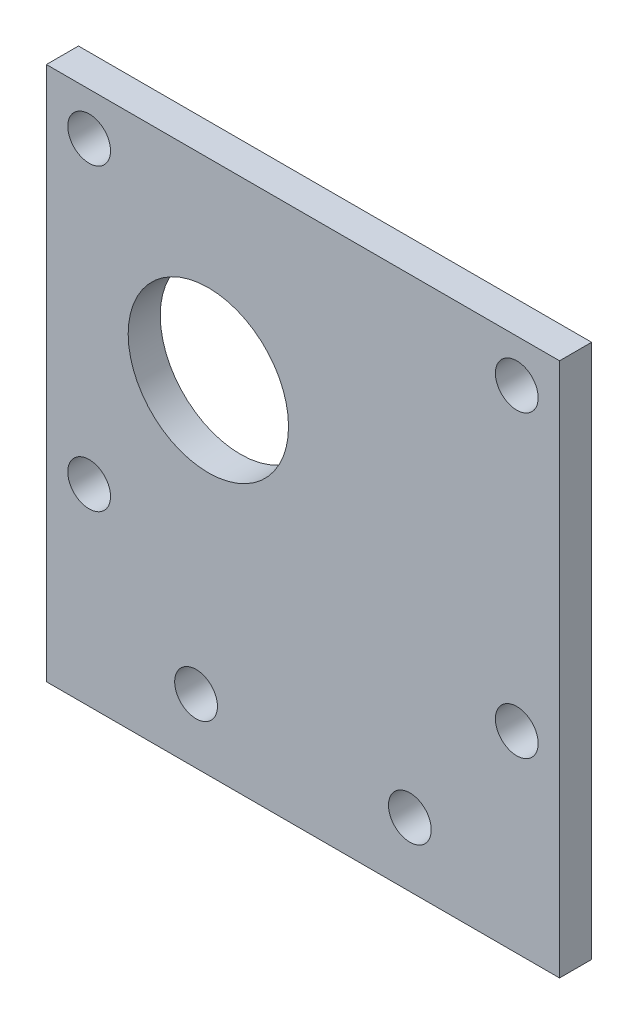
from build123d import *

# Parameters (mm, degrees)
SKETCH2_W           = 48
SKETCH2_H           = 50
SKETCH2_R           = 2
SKETCH2_R_2         = 7.5
BOSS_EXTRUDE2_DEPTH = 3


with BuildPart() as part:
    # Sketch2 → Boss-Extrude2 (new body)
    with BuildSketch(Plane.XY):
        with Locations((24, 25)):
            Rectangle(SKETCH2_W, SKETCH2_H)
        with Locations((4, 46)):
            Circle(SKETCH2_R, mode=Mode.SUBTRACT)
        with Locations((44, 46)):
            Circle(SKETCH2_R, mode=Mode.SUBTRACT)
        with Locations((44, 18)):
            Circle(SKETCH2_R, mode=Mode.SUBTRACT)
        with Locations((4, 18)):
            Circle(SKETCH2_R, mode=Mode.SUBTRACT)
        with Locations((15.15, 32)):
            Circle(SKETCH2_R_2, mode=Mode.SUBTRACT)
        with Locations((14, 6)):
            Circle(SKETCH2_R, mode=Mode.SUBTRACT)
        with Locations((34, 6)):
            Circle(SKETCH2_R, mode=Mode.SUBTRACT)
    extrude(amount=BOSS_EXTRUDE2_DEPTH)


solid = part.part
